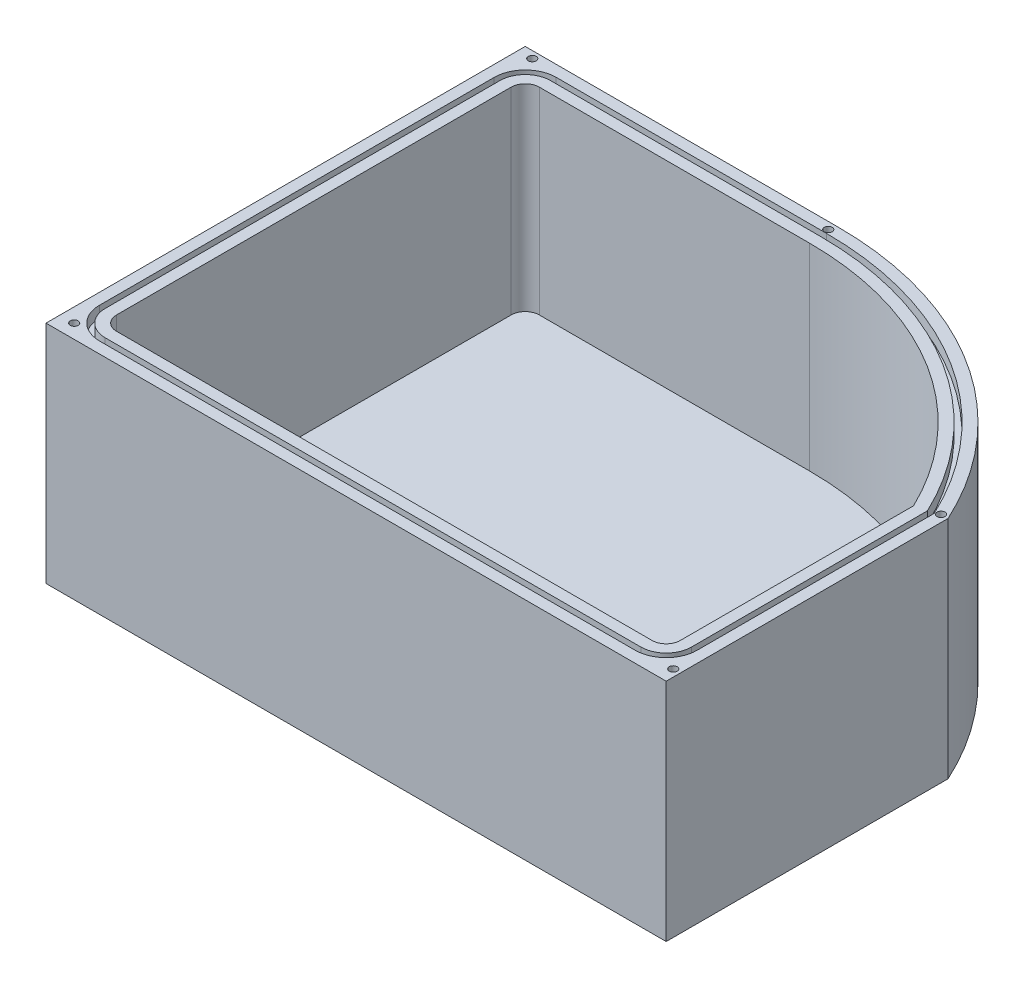
from build123d import *

# Parameters (mm, degrees)
BOSS_EXTRUDE1_DEPTH       = 50.8
SHELL1_T                  = -6.35
FILLET1_R                 = 3.175
CUT_EXTRUDE1_DEPTH        = 2.54
F_2_64_TAPPED_HOLE1_D     = 1.778
F_2_64_TAPPED_HOLE1_DEPTH = 6.35
F_2_64_TAPPED_HOLE1_TIP   = 0.53416509


with BuildPart() as part:
    # Sketch2 → Boss-Extrude1 (new body)
    with BuildSketch(Plane(origin=(0, 0, 0), x_dir=(1, 0, 0), z_dir=(0, 1, 0))):
        with BuildLine():
            Line((0, 0), (139.7, 0))
            Line((139.7, 0), (139.7, 63.5))
            ThreePointArc((139.7, 63.5), (111.582381507, 95.881856359), (70.429678072, 107.95))
            Line((70.429678072, 107.95), (0, 107.95))
            Line((0, 107.95), (0, 0))
        make_face()
    extrude(amount=BOSS_EXTRUDE1_DEPTH)

    # Shell1
    shell1_openings = [part.faces().sort_by_distance(p)[0] for p in [
        (71.269444109, 50.8, -57.911371272),
    ]]
    offset(amount=SHELL1_T, openings=shell1_openings, kind=Kind.INTERSECTION)

    # Fillet1
    fillet1_edges = [part.edges().sort_by_distance(p)[0] for p in [
        (6.35, 28.575, -101.6),
        (6.35, 28.575, -6.35),
        (133.35, 28.575, -6.35),
    ]]
    fillet(fillet1_edges, radius=FILLET1_R)

    # Sketch4 → Cut-Extrude1 (cut)
    with BuildSketch(Plane(origin=(0, 50.8, 0), x_dir=(1, 0, 0), z_dir=(0, 1, 0))):
        with BuildLine():
            Line((2.54, 98.425), (2.54, 9.525))
            ThreePointArc((2.54, 9.525), (4.585859133, 4.585859133), (9.525, 2.54))
            Line((9.525, 2.54), (130.175, 2.54))
            ThreePointArc((130.175, 2.54), (135.114140867, 4.585859133), (137.16, 9.525))
            Line((137.16, 9.525), (137.16, 62.940699502))
            ThreePointArc((137.16, 62.940699502), (109.97894276, 93.892185853), (70.429678072, 105.41))
            Line((70.429678072, 105.41), (9.525, 105.41))
            ThreePointArc((9.525, 105.41), (4.585859133, 103.364140867), (2.54, 98.425))
        make_face()
        with BuildLine():
            Line((9.525, 3.81), (130.175, 3.81))
            ThreePointArc((130.175, 3.81), (134.216115254, 5.483884746), (135.89, 9.525))
            Line((135.89, 9.525), (135.89, 62.657254053))
            ThreePointArc((135.89, 62.657254053), (109.178458563, 92.896088268), (70.429678072, 104.14))
            Line((70.429678072, 104.14), (9.525, 104.14))
            ThreePointArc((9.525, 104.14), (5.483884746, 102.466115254), (3.81, 98.425))
            Line((3.81, 98.425), (3.81, 9.525))
            ThreePointArc((3.81, 9.525), (5.483884746, 5.483884746), (9.525, 3.81))
        make_face(mode=Mode.SUBTRACT)
    extrude(amount=-CUT_EXTRUDE1_DEPTH, mode=Mode.SUBTRACT)

    # #2-64 Tapped Hole1
    with Locations(Plane(origin=(0, 50.8, 0), x_dir=(1, 0, 0), z_dir=(0, 1, 0))):
        with Locations((3.175, 3.175), (3.175, 106.3625), (69.85, 106.3625), (138.1125, 63.5), (138.1125, 3.175)):
            Hole(F_2_64_TAPPED_HOLE1_D / 2, depth=F_2_64_TAPPED_HOLE1_DEPTH)
            with Locations((0, 0, -(F_2_64_TAPPED_HOLE1_DEPTH + F_2_64_TAPPED_HOLE1_TIP / 2))):  # 118° drill point
                Cone(0, F_2_64_TAPPED_HOLE1_D / 2, F_2_64_TAPPED_HOLE1_TIP, mode=Mode.SUBTRACT)


solid = part.part
